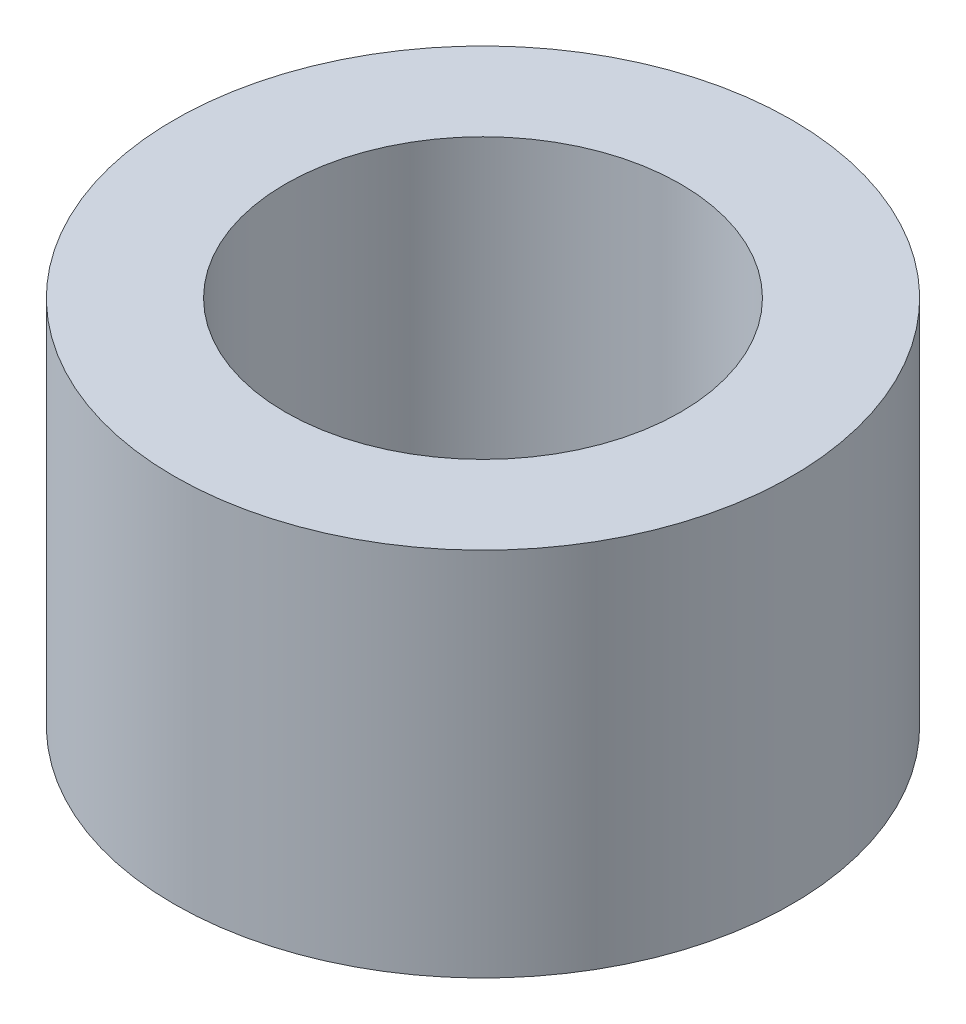
from build123d import *

# Parameters (mm, degrees)
SKETCH1_R           = 2.5
SKETCH1_R_2         = 1.6
BOSS_EXTRUDE1_DEPTH = 3


with BuildPart() as part:
    # Sketch1 → Boss-Extrude1 (new body)
    with BuildSketch(Plane(origin=(0, 0, 0), x_dir=(1, 0, 0), z_dir=(0, 1, 0))):
        Circle(SKETCH1_R)
        Circle(SKETCH1_R_2, mode=Mode.SUBTRACT)
    extrude(amount=BOSS_EXTRUDE1_DEPTH)


solid = part.part
